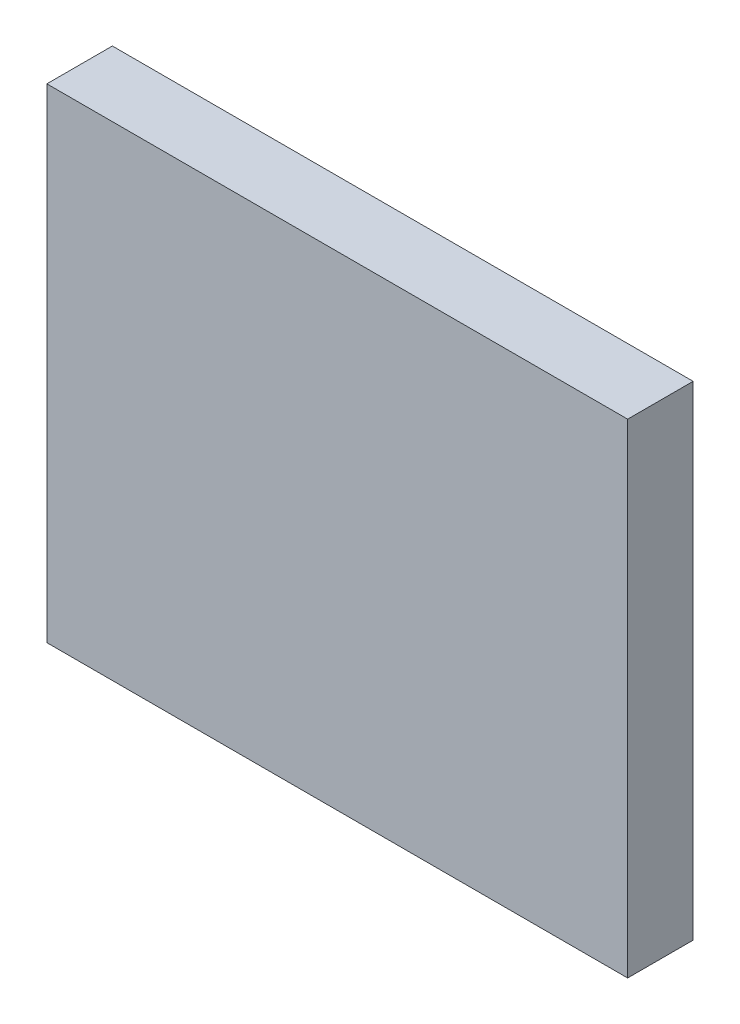
from build123d import *

# Parameters (mm, degrees)
SKETCH5_W           = 180
SKETCH5_H           = 150
BOSS_EXTRUDE1_DEPTH = 20.3


with BuildPart() as part:
    # Sketch5 → Boss-Extrude1 (new body)
    with BuildSketch(Plane.XY):
        Rectangle(SKETCH5_W, SKETCH5_H)
    extrude(amount=BOSS_EXTRUDE1_DEPTH)


solid = part.part
